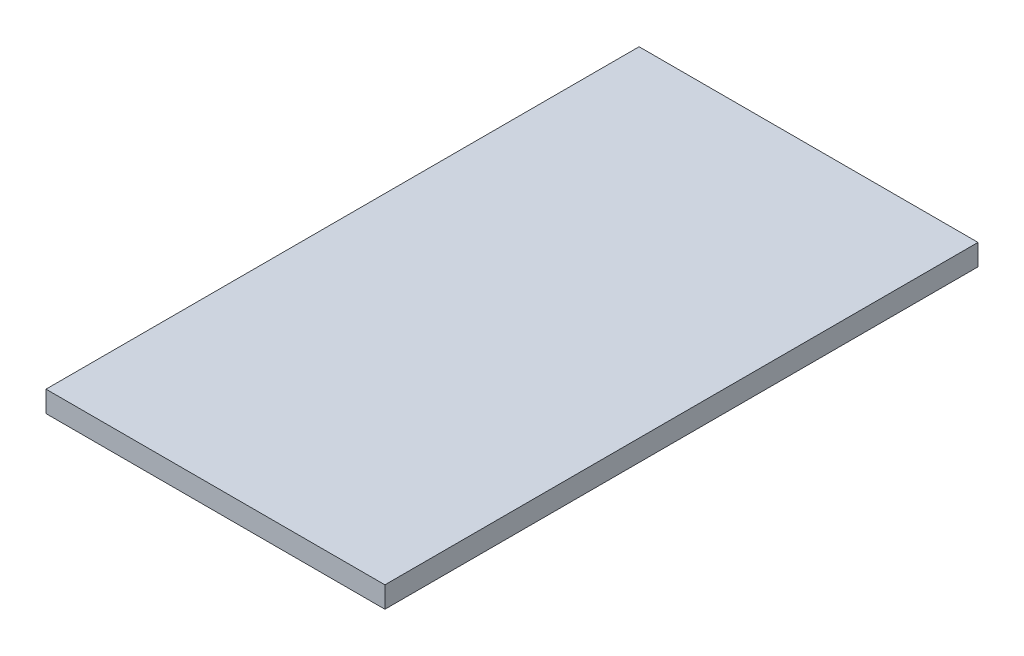
from build123d import *

# Parameters (mm, degrees)
SKETCH1_W           = 160
SKETCH1_H           = 280
BOSS_EXTRUDE1_DEPTH = 10


with BuildPart() as part:
    # Sketch1 → Boss-Extrude1 (new body)
    with BuildSketch(Plane(origin=(0, 0, 0), x_dir=(1, 0, 0), z_dir=(0, 1, 0))):
        with Locations((9.704918033, -96.721311475)):
            Rectangle(SKETCH1_W, SKETCH1_H)
    extrude(amount=BOSS_EXTRUDE1_DEPTH)


solid = part.part
